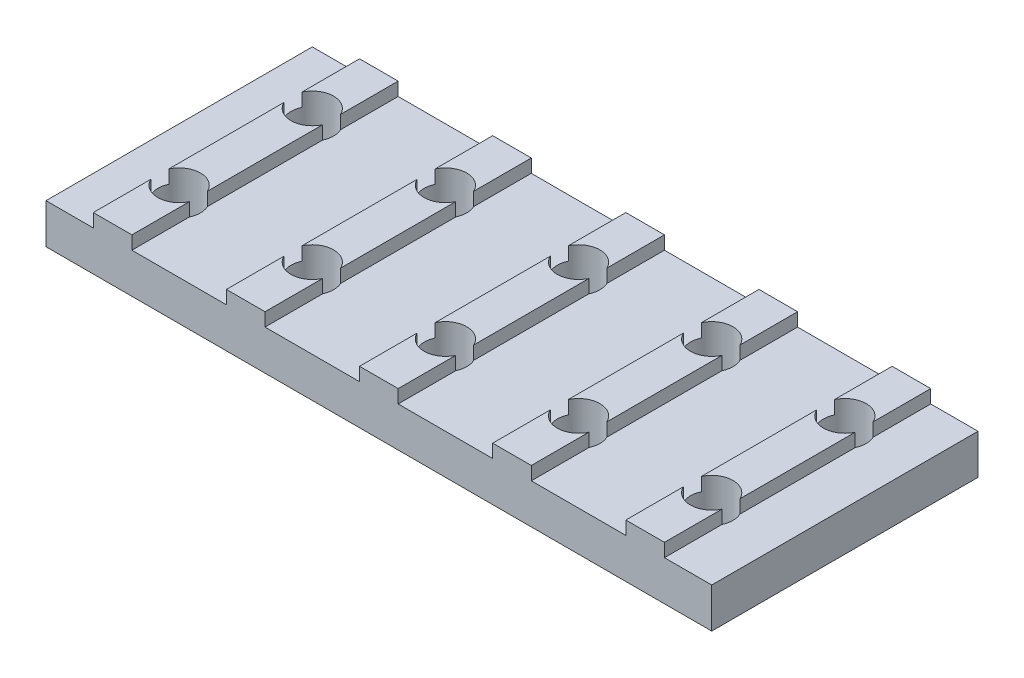
from build123d import *

# Parameters (mm, degrees)
MAIN_DEPTH                 = 20
ESQUISSE2_R                = 1.6
TOPHOLE_DEPTH              = 22
R_P_TITION_LIN_AIRE1_COUNT = 5
R_P_TITION_LIN_AIRE1_PITCH = 10


with BuildPart() as part:
    # Esquisse1 → Main (new body)
    with BuildSketch(Plane.XY):
        Polygon((-5, 0), (-5, 3), (-1.45, 3), (-1.45, 4), (1.45, 4), (1.45, 3), (5, 3), (5, 0), align=None)
    main = extrude(amount=MAIN_DEPTH)

    # Esquisse2 → TopHole (cut, through all)
    with BuildSketch(Plane(origin=(0, 4, 0), x_dir=(1, 0, 0), z_dir=(0, 1, 0))):
        with Locations((0, -5)):
            Circle(ESQUISSE2_R)
        with Locations((0, -15)):
            Circle(ESQUISSE2_R)
    tophole = extrude(amount=-TOPHOLE_DEPTH, mode=Mode.SUBTRACT)

    # Répétition linéaire1: Main, TopHole ×5
    with Locations(*[(-i * R_P_TITION_LIN_AIRE1_PITCH, 0, 0) for i in range(1, R_P_TITION_LIN_AIRE1_COUNT)]):
        add(main)
        add(tophole, mode=Mode.SUBTRACT)


solid = part.part
